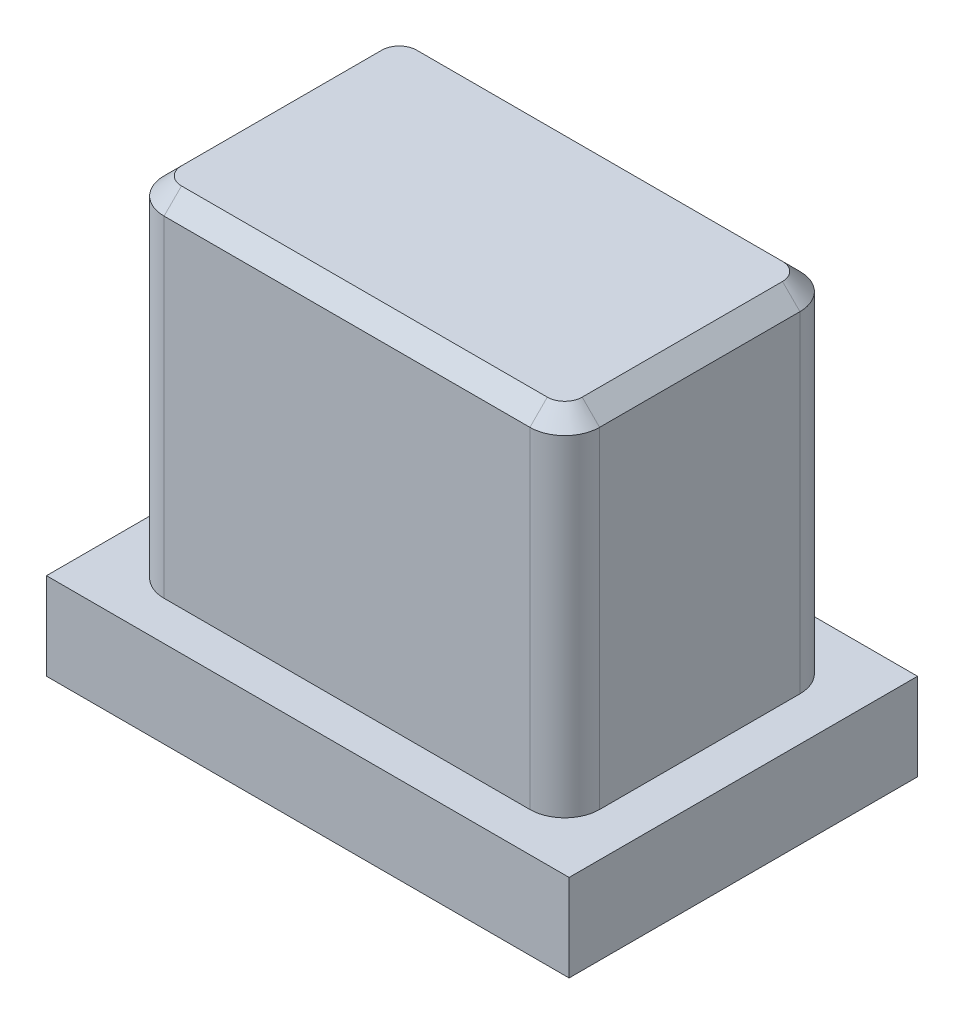
from build123d import *

# Parameters (mm, degrees)
JIG_SKETCH_W   = 25
JIG_SKETCH_H   = 15.5
INSERT_DEPTH   = 20
SKETCH1_3_W    = 30
SKETCH1_3_H    = 20
BASE_DEPTH     = 5
ROUND_EDGES_R  = 2
CHAMFER_2_SIZE = 1


with BuildPart() as part:
    # jig_sketch → insert (new body)
    with BuildSketch(Plane(origin=(0, 0, 0), x_dir=(1, 0, 0), z_dir=(0, 1, 0))):
        with Locations((12.5, 8.590078954)):
            Rectangle(JIG_SKETCH_W, JIG_SKETCH_H)
    extrude(amount=INSERT_DEPTH)

    # Sketch1_3 → base (add)
    with BuildSketch(Plane(origin=(0, 0, 0), x_dir=(1, 0, 0), z_dir=(0, 1, 0))):
        with Locations((12.5, 8.590078954)):
            Rectangle(SKETCH1_3_W, SKETCH1_3_H)
    extrude(amount=-BASE_DEPTH)

    # round_edges
    round_edges_edges = [part.edges().sort_by_distance(p)[0] for p in [
        (25, 10, -0.840078954),
        (25, 10, -16.340078954),
        (0, 10, -16.340078954),
        (0, 10, -0.840078954),
    ]]
    fillet(round_edges_edges, radius=ROUND_EDGES_R)

    # chamfer 2
    chamfer_2_edges = [part.edges().sort_by_distance(p)[0] for p in [
        (12.5, 20, -16.340078954),
        (0.585786438, 20, -15.754292517),
        (24.414213562, 20, -15.754292517),
        (0, 20, -8.590078954),
        (25, 20, -8.590078954),
        (0.585786438, 20, -1.425865392),
        (24.414213562, 20, -1.425865392),
        (12.5, 20, -0.840078954),
    ]]
    chamfer(chamfer_2_edges, length=CHAMFER_2_SIZE)


solid = part.part
